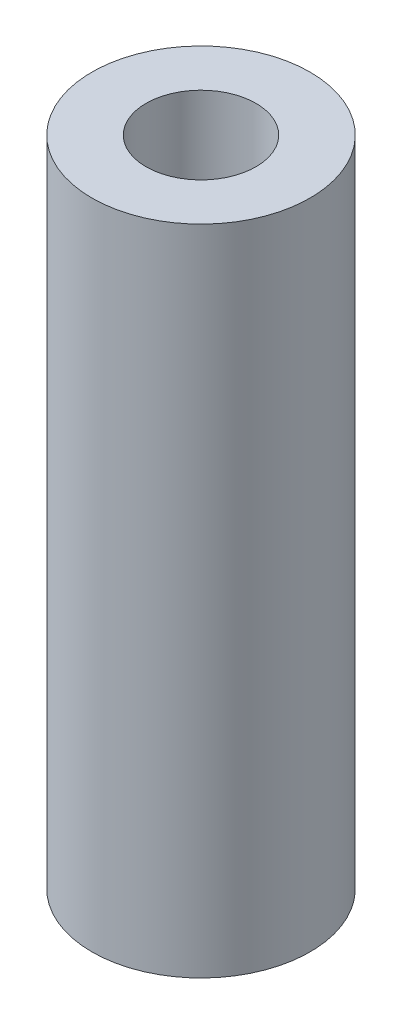
from build123d import *

# Parameters (mm, degrees)
SKETCH1_R           = 4.7625
SKETCH1_R_2         = 2.4
BOSS_EXTRUDE1_DEPTH = 14.25


with BuildPart() as part:
    # Sketch1 → Boss-Extrude1 (new body, symmetric)
    with BuildSketch(Plane(origin=(0, 0, 0), x_dir=(1, 0, 0), z_dir=(0, 1, 0))):
        Circle(SKETCH1_R)
        Circle(SKETCH1_R_2, mode=Mode.SUBTRACT)
    extrude(amount=BOSS_EXTRUDE1_DEPTH, both=True)


solid = part.part
